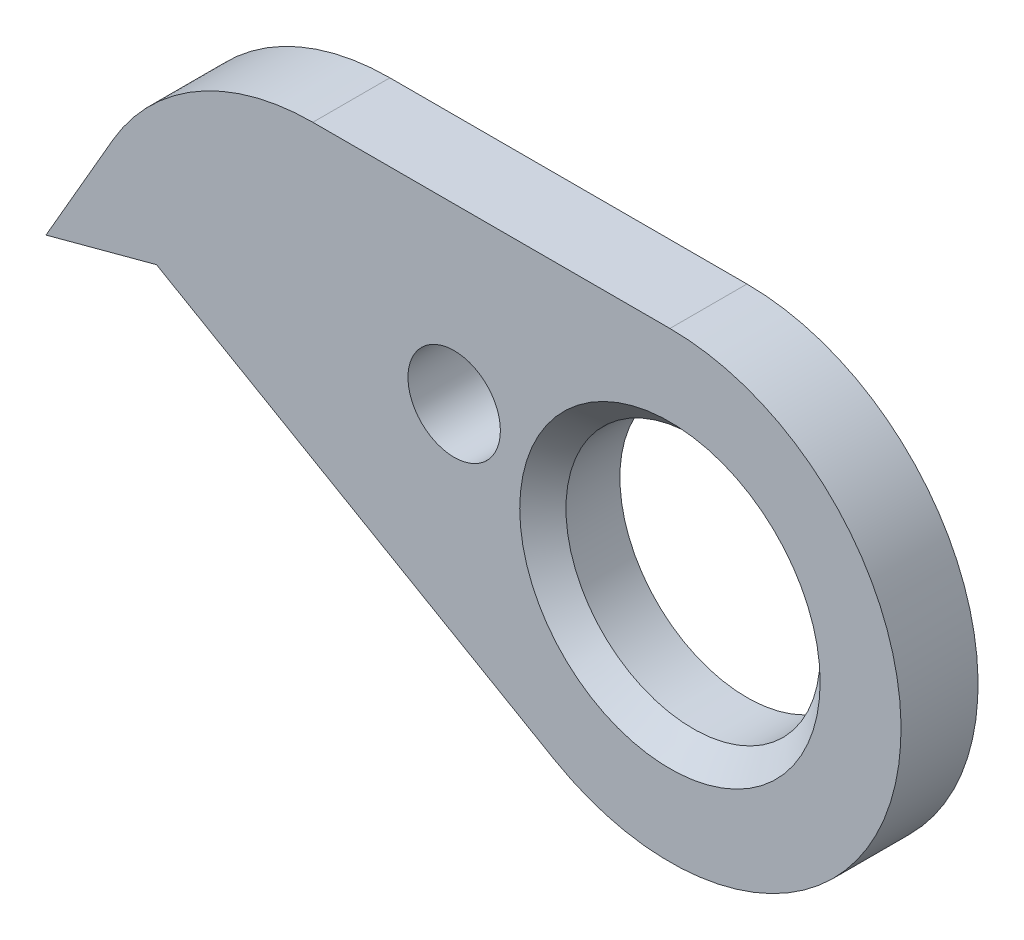
from build123d import *

# Parameters (mm, degrees)
BOSS_EXTRUDE1_DEPTH        = 1
CUT_EXTRUDE1_REACH         = 3
SKETCH2_R                  = 1.65
CHAMFER1_SIZE              = 0.3
F_1_2_1_2_DIAMETER_HOLE1_D = 1.2


with BuildPart() as part:
    # Sketch1 → Boss-Extrude1 (new body)
    with BuildSketch(Plane.XY):
        with BuildLine():
            Line((0, 3), (-4.635898385, 3))
            ThreePointArc((-4.635898385, 3), (-6.135898385, 2.598076211), (-7.233974596, 1.5))
            Line((-7.233974596, 1.5), (-8.1, 0))
            Line((-8.1, 0), (-6.665673326, 0.384326674))
            Line((-6.665673326, 0.384326674), (-1.5, -2.598076211))
            ThreePointArc((-1.5, -2.598076211), (2.897777479, -0.776457135), (0, 3))
        make_face()
    extrude(amount=-BOSS_EXTRUDE1_DEPTH)

    # Sketch2 → Cut-Extrude1 (cut, up to next)
    with BuildSketch(Plane.XY, mode=Mode.PRIVATE) as cut_extrude1_sk1:
        Circle(SKETCH2_R)
    cut_extrude1_tool1 = extrude(cut_extrude1_sk1.sketch, amount=-CUT_EXTRUDE1_REACH, mode=Mode.PRIVATE) & part.part
    add(cut_extrude1_tool1.solids().sort_by_distance((0, 0, 0))[0], mode=Mode.SUBTRACT)

    # Chamfer1
    chamfer1_edges = [part.edges().sort_by_distance(p)[0] for p in [
        (-1.65, 0, 0),
    ]]
    chamfer(chamfer1_edges, length=CHAMFER1_SIZE)

    # Ø1.2 (1.2) Diameter Hole1 (through all)
    with Locations(Plane.XY):
        with Locations((-2.801184896, 0.750575231)):
            Hole(F_1_2_1_2_DIAMETER_HOLE1_D / 2)


solid = part.part
